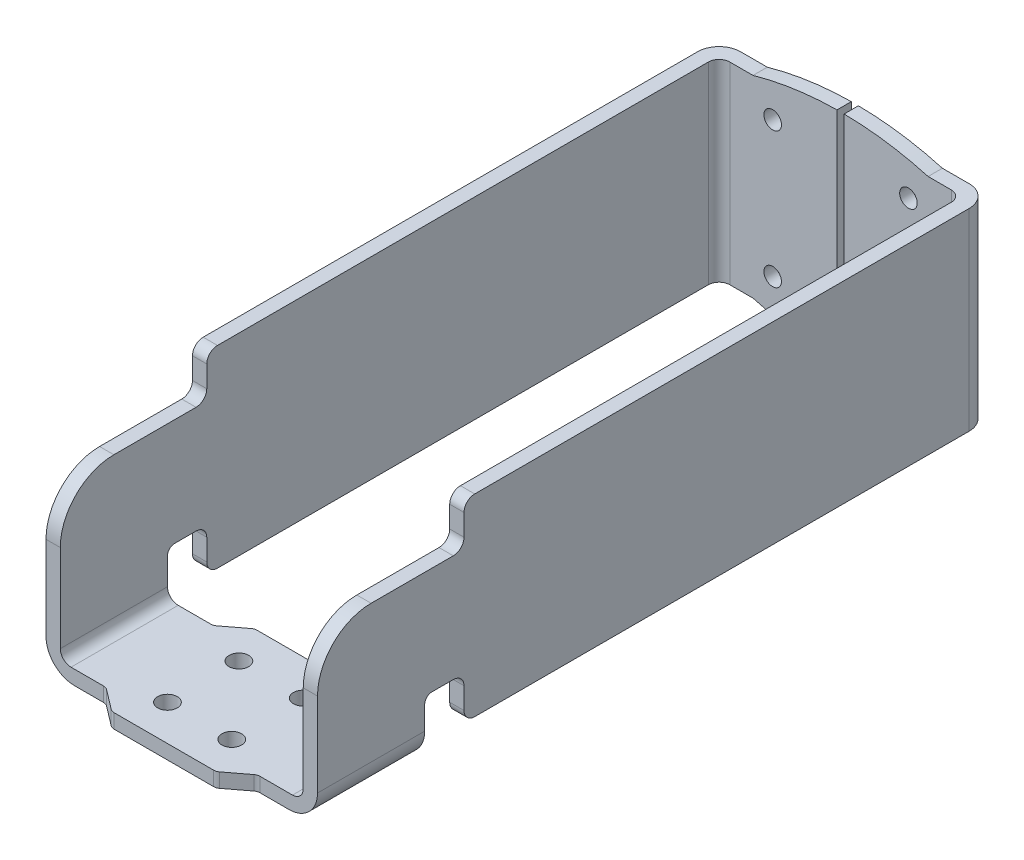
from build123d import *

# Parameters (mm, degrees)
BOSS_EXTRUDE1_DEPTH     = 193.4
CUT_EXTRUDE1_DEPTH      = 38
CUT_EXTRUDE1_DEPTH_BACK = 38
BOSS_EXTRUDE2_DEPTH     = 4.5
CUT_EXTRUDE2_DEPTH      = 40
CUT_EXTRUDE3_DEPTH      = 42
CUT_EXTRUDE4_DEPTH      = 81.5
CUT_EXTRUDE5_DEPTH      = 81.5
SKETCH8_W               = 2
SKETCH8_H               = 108
CUT_EXTRUDE6_DEPTH      = 4
SKETCH9_W               = 2.75
SKETCH9_H               = 4
LPATTERN1_COUNT         = 2
LPATTERN1_PITCH         = 20
LPATTERN1_COUNT_DIR2    = 2
LPATTERN1_PITCH_DIR2    = 18
LPATTERN2_COUNT         = 2
LPATTERN2_PITCH         = 38
LPATTERN2_COUNT_DIR2    = 2
LPATTERN2_PITCH_DIR2    = 38


with BuildPart() as part:
    # Sketch1 → Boss-Extrude1 (new body)
    with BuildSketch(Plane.XY.offset(-193.4)):
        with BuildLine():
            Line((-38, 58.5), (-38, 4.5))
            Line((-38, 4.5), (-24.503877244, 4.5))
            ThreePointArc((-24.503877244, 4.5), (0, 1.1), (24.503877244, 4.5))
            Line((24.503877244, 4.5), (38, 4.5))
            Line((38, 4.5), (38, 58.5))
            Line((38, 58.5), (24.503877244, 58.5))
            ThreePointArc((24.503877244, 58.5), (0, 61.9), (-24.503877244, 58.5))
            Line((-24.503877244, 58.5), (-38, 58.5))
        make_face()
    extrude(amount=BOSS_EXTRUDE1_DEPTH)

    # Sketch2 → Cut-Extrude1 (cut, two sides: drawn at the far end of the back side and taken through both)
    with BuildSketch(Plane(origin=(0, 0, 0), x_dir=(0, 0, -1), z_dir=(1, 0, 0)).offset(-CUT_EXTRUDE1_DEPTH_BACK)):
        with BuildLine():
            Line((0, -5), (189.4, -5))
            Line((189.4, -5), (189.4, 4.5))
            Line((189.4, 4.5), (49, 4.5))
            ThreePointArc((49, 4.5), (46.878679656, 5.378679656), (46, 7.5))
            Line((46, 7.5), (46, 13.5))
            ThreePointArc((46, 13.5), (45.121320344, 15.621320344), (43, 16.5))
            Line((43, 16.5), (37, 16.5))
            ThreePointArc((37, 16.5), (35.585786438, 15.914213562), (35, 14.5))
            Line((35, 14.5), (35, 0))
            Line((35, 0), (5, 0))
            Line((5, 0), (5, 31.5))
            ThreePointArc((5, 31.5), (9.393398282, 42.106601718), (20, 46.5))
            Line((20, 46.5), (43, 46.5))
            ThreePointArc((43, 46.5), (45.121320344, 47.378679656), (46, 49.5))
            Line((46, 49.5), (46, 55.5))
            ThreePointArc((46, 55.5), (46.878679656, 57.621320344), (49, 58.5))
            Line((49, 58.5), (189.4, 58.5))
            Line((189.4, 58.5), (189.4, 63.5))
            Line((189.4, 63.5), (0, 63.5))
            Line((0, 63.5), (0, -5))
        make_face()
    extrude(amount=CUT_EXTRUDE1_DEPTH + CUT_EXTRUDE1_DEPTH_BACK, mode=Mode.SUBTRACT)

    # Sketch3 → Boss-Extrude2 (add)
    with BuildSketch(Plane(origin=(0, 0, 0), x_dir=(1, 0, 0), z_dir=(0, 1, 0))):
        with BuildLine():
            Line((-38, 5), (-21.865, 5))
            ThreePointArc((-21.865, 5), (-21.226384959, 4.895302306), (-20.654631441, 4.59217083))
            Line((-20.654631441, 4.59217083), (-15.150368559, 0.40782917))
            ThreePointArc((-15.150368559, 0.40782917), (-14.578615041, 0.104697694), (-13.94, 0))
            Line((-13.94, 0), (13.94, 0))
            ThreePointArc((13.94, 0), (14.578615041, 0.104697694), (15.150368559, 0.40782917))
            Line((15.150368559, 0.40782917), (20.654631441, 4.59217083))
            ThreePointArc((20.654631441, 4.59217083), (21.226384959, 4.895302306), (21.865, 5))
            Line((21.865, 5), (38, 5))
            Line((38, 5), (38, 35))
            Line((38, 35), (21.865, 35))
            ThreePointArc((21.865, 35), (21.226384959, 35.104697694), (20.654631441, 35.40782917))
            Line((20.654631441, 35.40782917), (15.150368559, 39.59217083))
            ThreePointArc((15.150368559, 39.59217083), (14.578615041, 39.895302306), (13.94, 40))
            Line((13.94, 40), (-13.94, 40))
            ThreePointArc((-13.94, 40), (-14.578615041, 39.895302306), (-15.150368559, 39.59217083))
            Line((-15.150368559, 39.59217083), (-20.654631441, 35.40782917))
            ThreePointArc((-20.654631441, 35.40782917), (-21.226384959, 35.104697694), (-21.865, 35))
            Line((-21.865, 35), (-38, 35))
            Line((-38, 35), (-38, 5))
        make_face()
    extrude(amount=BOSS_EXTRUDE2_DEPTH)

    # Sketch4 → Cut-Extrude2 (cut)
    with BuildSketch(Plane.XY):
        with BuildLine():
            Line((-38, -5), (38, -5))
            Line((38, -5), (38, 8))
            ThreePointArc((38, 8), (35.656854249, 2.343145751), (30, 0))
            Line((30, 0), (-30, 0))
            ThreePointArc((-30, 0), (-35.656854249, 2.343145751), (-38, 8))
            Line((-38, 8), (-38, -5))
        make_face()
    extrude(amount=-CUT_EXTRUDE2_DEPTH, mode=Mode.SUBTRACT)

    # Sketch5 → Cut-Extrude3 (cut)
    with BuildSketch(Plane.XY):
        with BuildLine():
            Line((-31, 4), (31, 4))
            ThreePointArc((31, 4), (33.121320344, 4.878679656), (34, 7))
            Line((34, 7), (34, 62))
            Line((34, 62), (-34, 62))
            Line((-34, 62), (-34, 7))
            ThreePointArc((-34, 7), (-33.121320344, 4.878679656), (-31, 4))
        make_face()
    extrude(amount=-CUT_EXTRUDE3_DEPTH, mode=Mode.SUBTRACT)

    # Sketch6 → Cut-Extrude4 (cut)
    with BuildSketch(Plane(origin=(0, 0, 0), x_dir=(1, 0, 0), z_dir=(0, 1, 0))):
        with BuildLine():
            Line((-34, 186.4), (-34, 41))
            Line((-34, 41), (34, 41))
            Line((34, 41), (34, 186.4))
            ThreePointArc((34, 186.4), (33.121320344, 188.521320344), (31, 189.4))
            Line((31, 189.4), (-31, 189.4))
            ThreePointArc((-31, 189.4), (-33.121320344, 188.521320344), (-34, 186.4))
        make_face()
    extrude(amount=CUT_EXTRUDE4_DEPTH, mode=Mode.SUBTRACT)

    # Sketch7 → Cut-Extrude5 (cut)
    with BuildSketch(Plane(origin=(0, 0, 0), x_dir=(1, 0, 0), z_dir=(0, 1, 0))):
        with BuildLine():
            Line((-32, 193.4), (32, 193.4))
            ThreePointArc((32, 193.4), (36.242640687, 191.642640687), (38, 187.4))
            Line((38, 187.4), (38, 198.4))
            Line((38, 198.4), (-38, 198.4))
            Line((-38, 198.4), (-38, 187.4))
            ThreePointArc((-38, 187.4), (-36.242640687, 191.642640687), (-32, 193.4))
        make_face()
    extrude(amount=CUT_EXTRUDE5_DEPTH, mode=Mode.SUBTRACT)

    # Sketch8 → Cut-Extrude6 (cut)
    with BuildSketch(Plane.XY.offset(-193.4)):
        with Locations((0, 54)):
            Rectangle(SKETCH8_W, SKETCH8_H)
    extrude(amount=CUT_EXTRUDE6_DEPTH, mode=Mode.SUBTRACT)

    # Sketch9 → Cut-Revolve1 (revolve, cut)
    with BuildSketch(Plane(origin=(9, 0, 0), x_dir=(0, 0, -1), z_dir=(1, 0, 0))):
        with Locations((11.375, 2)):
            Rectangle(SKETCH9_W, SKETCH9_H)
    cut_revolve1 = revolve(axis=Axis((9, 0, -10), (0, 1, 0)), mode=Mode.SUBTRACT)

    # LPattern1: Cut-Revolve1 2 × 2
    with Locations(*[(-j * LPATTERN1_PITCH_DIR2, 0, -i * LPATTERN1_PITCH) for i in range(LPATTERN1_COUNT) for j in range(LPATTERN1_COUNT_DIR2) if (i, j) != (0, 0)]):
        add(cut_revolve1, mode=Mode.SUBTRACT)

    # Sketch11 → Cut-Revolve2 (revolve, cut)
    with BuildSketch(Plane(origin=(19, 0, 0), x_dir=(0, 0, -1), z_dir=(1, 0, 0))):
        Polygon((189.4, 12.5), (189.4, 14.9585), (192.8585, 14.9585), (193.4, 15.5), (193.4, 12.5), align=None)
    cut_revolve2 = revolve(axis=Axis((19, 12.5, -193.4), (0, 0, 1)), mode=Mode.SUBTRACT)

    # LPattern2: Cut-Revolve2 2 × 2
    with Locations(*[(-j * LPATTERN2_PITCH_DIR2, i * LPATTERN2_PITCH, 0) for i in range(LPATTERN2_COUNT) for j in range(LPATTERN2_COUNT_DIR2) if (i, j) != (0, 0)]):
        add(cut_revolve2, mode=Mode.SUBTRACT)


solid = part.part
